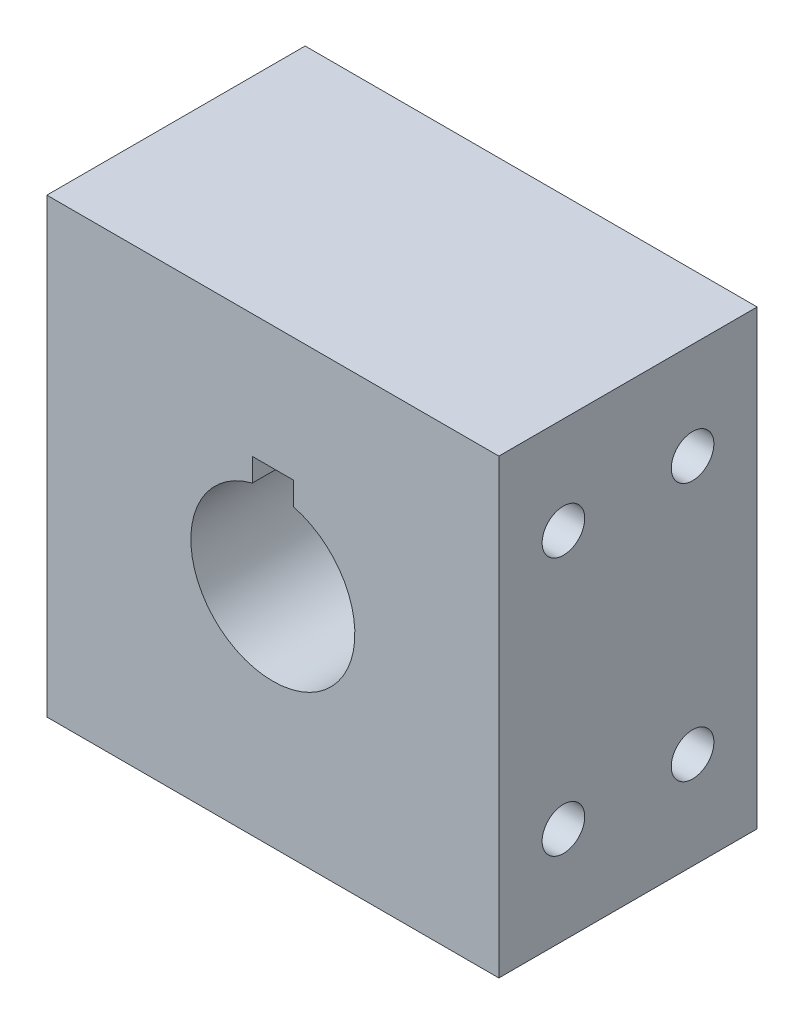
from build123d import *

# Parameters (mm, degrees)
SKETCH1_W                      = 35
SKETCH1_H                      = 35
BOSS_EXTRUDE1_DEPTH            = 20
CUT_EXTRUDE1_DEPTH             = 54.38539126
M4X0_7_TAPPED_HOLE1_AT_2_COUNT = 2
M4X0_7_TAPPED_HOLE1_AT_2_PITCH = 22.360679775
M4X0_7_TAPPED_HOLE1_AT_3_COUNT = 2
M4X0_7_TAPPED_HOLE1_AT_3_PITCH = 20
M4X0_7_TAPPED_HOLE1_AT_4_COUNT = 2
M4X0_7_TAPPED_HOLE1_AT_4_PITCH = 10


with BuildPart() as part:
    # Sketch1 → Boss-Extrude1 (new body)
    with BuildSketch(Plane.XY):
        with Locations((-17.5, 17.5)):
            Rectangle(SKETCH1_W, SKETCH1_H)
    extrude(amount=BOSS_EXTRUDE1_DEPTH)

    # Sketch2 → Cut-Extrude1 (cut, through all)
    with BuildSketch(Plane.XY.offset(20)):
        with BuildLine():
            Line((-15.9125, 25.4375), (-19.0875, 25.4375))
            Line((-19.0875, 25.4375), (-19.0875, 23.648361062))
            ThreePointArc((-19.0875, 23.648361062), (-17.5, 11.15), (-15.9125, 23.648361062))
            Line((-15.9125, 23.648361062), (-15.9125, 25.4375))
        make_face()
    extrude(amount=-CUT_EXTRUDE1_DEPTH, mode=Mode.SUBTRACT)

    # Sketch4 → M4x0.7 Tapped Hole1 (revolve, cut)
    with BuildSketch(Plane(origin=(-35, 27.5, 5), x_dir=(0, 0, 1), z_dir=(0, 1, 0))):
        Polygon((0, 0), (0, 10.991420021), (1.65, 10), (1.65, 0), align=None)
    m4x0_7_tapped_hole1 = revolve(axis=Axis((-41.35, 27.5, 5), (1, 0, 0)), mode=Mode.SUBTRACT)

    # M4x0.7 Tapped Hole1 at 2: M4x0.7 Tapped Hole1 ×2
    with Locations(*[Vector(0, -0.8944271909999159, 0.4472135954999581) * (i * M4X0_7_TAPPED_HOLE1_AT_2_PITCH) for i in range(1, M4X0_7_TAPPED_HOLE1_AT_2_COUNT)]):
        add(m4x0_7_tapped_hole1, mode=Mode.SUBTRACT)

    # M4x0.7 Tapped Hole1 at 3: M4x0.7 Tapped Hole1 ×2
    with Locations(*[(0, -i * M4X0_7_TAPPED_HOLE1_AT_3_PITCH, 0) for i in range(1, M4X0_7_TAPPED_HOLE1_AT_3_COUNT)]):
        add(m4x0_7_tapped_hole1, mode=Mode.SUBTRACT)

    # M4x0.7 Tapped Hole1 at 4: M4x0.7 Tapped Hole1 ×2
    with Locations(*[(0, 0, i * M4X0_7_TAPPED_HOLE1_AT_4_PITCH) for i in range(1, M4X0_7_TAPPED_HOLE1_AT_4_COUNT)]):
        add(m4x0_7_tapped_hole1, mode=Mode.SUBTRACT)

    # Mirror1: M4x0.7 Tapped Hole1 across plane
    add(m4x0_7_tapped_hole1.mirror(Plane.ZY.offset(17.5)), mode=Mode.SUBTRACT)

    # Mirror1 copy 1 sketch → Mirror1 copy 1 (revolve, cut)
    with BuildSketch(Plane(origin=(0, 7.5, 15), x_dir=(0, 0, 1), z_dir=(0, 1, 0))):
        Polygon((0, 0), (0, -10.991420021), (1.65, -10), (1.65, 0), align=None)
    revolve(axis=Axis((6.35, 7.5, 15), (1, 0, 0)), mode=Mode.SUBTRACT)

    # Mirror1 copy 2 sketch → Mirror1 copy 2 (revolve, cut)
    with BuildSketch(Plane(origin=(0, 7.5, 5), x_dir=(0, 0, 1), z_dir=(0, 1, 0))):
        Polygon((0, 0), (0, -10.991420021), (1.65, -10), (1.65, 0), align=None)
    revolve(axis=Axis((6.35, 7.5, 5), (1, 0, 0)), mode=Mode.SUBTRACT)

    # Mirror1 copy 3 sketch → Mirror1 copy 3 (revolve, cut)
    with BuildSketch(Plane(origin=(0, 27.5, 15), x_dir=(0, 0, 1), z_dir=(0, 1, 0))):
        Polygon((0, 0), (0, -10.991420021), (1.65, -10), (1.65, 0), align=None)
    revolve(axis=Axis((6.35, 27.5, 15), (1, 0, 0)), mode=Mode.SUBTRACT)


solid = part.part
